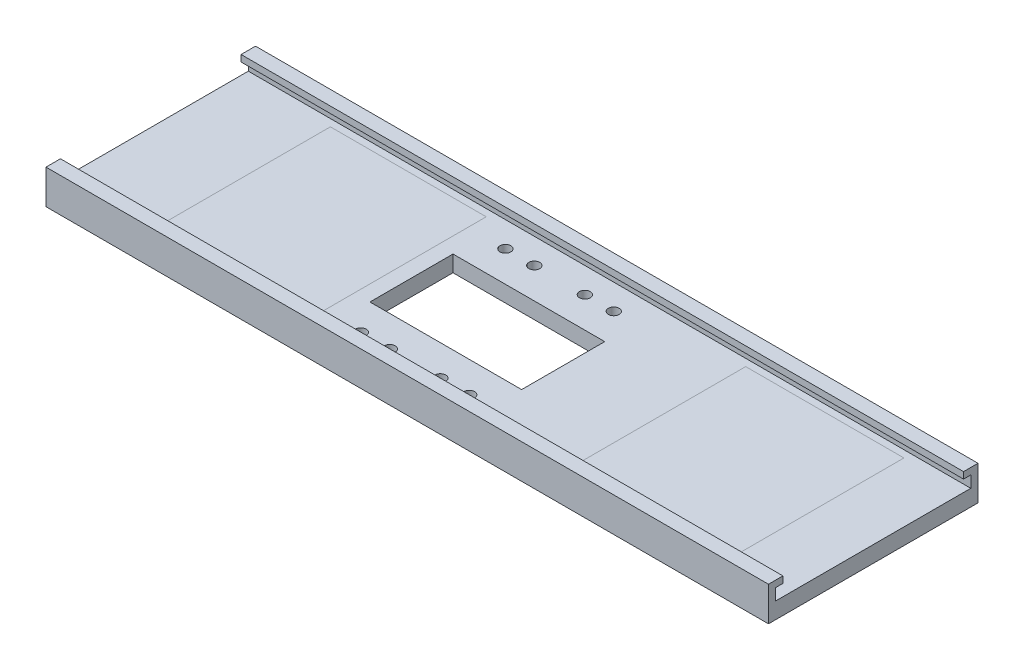
from build123d import *

# Parameters (mm, degrees)
EXTRUDE_1_DEPTH      = 180
EXTRUDE_1_DEPTH_BACK = 20
SKETCH_2_W           = 42
SKETCH_2_H           = 23
CUT_EXTRUDE_1_DEPTH  = 5.5
SKETCH_4_R           = 1.5
CUT_EXTRUDE_2_DEPTH  = 5.5
SKETCH_5_W           = 2
SKETCH_5_H           = 2.2
CUT_EXTRUDE_3_DEPTH  = 225
SKETCH_6_R           = 3
CUT_EXTRUDE_4_DEPTH  = 3.5
SKETCH_7_W           = 2
SKETCH_7_H           = 1
CUT_EXTRUDE_5_DEPTH  = 200


with BuildPart() as part:
    # 草图1 → 凸台-拉伸1 (new body, two sides)
    with BuildSketch(Plane(origin=(0, 0, 0), x_dir=(0, 0, -1), z_dir=(1, 0, 0))) as extrude_1_sk:
        Polygon((-29, 0), (29, 0), (29, 9.5), (25, 9.5), (25, 4.5), (-25, 4.5), (-25, 9.5), (-29, 9.5), align=None)
    extrude(amount=EXTRUDE_1_DEPTH)
    extrude(extrude_1_sk.sketch, amount=-EXTRUDE_1_DEPTH_BACK)

    # 草图2 → 切除-拉伸1 (cut, through all)
    with BuildSketch(Plane(origin=(0, 4.5, 0), x_dir=(1, 0, 0), z_dir=(0, 1, 0))):
        with Locations((73.17, 0)):
            Rectangle(SKETCH_2_W, SKETCH_2_H)
    extrude(amount=-CUT_EXTRUDE_1_DEPTH, mode=Mode.SUBTRACT)

    # 草图4 → 切除-拉伸2 (cut, through all)
    with BuildSketch(Plane(origin=(0, 4.5, 0), x_dir=(1, 0, 0), z_dir=(0, 1, 0))):
        with Locations((66.17, 20)):
            Circle(SKETCH_4_R)
        with Locations((80.17, 20)):
            Circle(SKETCH_4_R)
        with Locations((88.17, 20)):
            Circle(SKETCH_4_R)
        with Locations((58.17, 20)):
            Circle(SKETCH_4_R)
        with Locations((88.17, -20)):
            Circle(SKETCH_4_R)
        with Locations((80.17, -20)):
            Circle(SKETCH_4_R)
        with Locations((66.17, -20)):
            Circle(SKETCH_4_R)
        with Locations((58.17, -20)):
            Circle(SKETCH_4_R)
    extrude(amount=-CUT_EXTRUDE_2_DEPTH, mode=Mode.SUBTRACT)

    # 草图5 → 切除-拉伸3 (cut)
    with BuildSketch(Plane(origin=(180, 0, 0), x_dir=(0, 0, -1), z_dir=(1, 0, 0))):
        with Locations((-26, 6.6)):
            Rectangle(SKETCH_5_W, SKETCH_5_H)
        with Locations((26, 6.6)):
            Rectangle(SKETCH_5_W, SKETCH_5_H)
    extrude(amount=-CUT_EXTRUDE_3_DEPTH, mode=Mode.SUBTRACT)

    # 草图6 → 切除-拉伸4 (cut)
    with BuildSketch(Plane(origin=(0, 0, 0), x_dir=(-1, 0, 0), z_dir=(0, -1, 0))):
        with Locations((-97.93, 5)):
            Circle(SKETCH_6_R)
        with Locations((-48.41, 5)):
            Circle(SKETCH_6_R)
        with Locations((-48.41, -5)):
            Circle(SKETCH_6_R)
        with Locations((-97.93, -5)):
            Circle(SKETCH_6_R)
    extrude(amount=-CUT_EXTRUDE_4_DEPTH, mode=Mode.SUBTRACT)

    # 草图7 → 切除-拉伸5 (cut)
    with BuildSketch(Plane(origin=(180, 0, 0), x_dir=(0, 0, -1), z_dir=(1, 0, 0))):
        with Locations((-26, 5)):
            Rectangle(SKETCH_7_W, SKETCH_7_H)
        with Locations((26, 5)):
            Rectangle(SKETCH_7_W, SKETCH_7_H)
    extrude(amount=-CUT_EXTRUDE_5_DEPTH, mode=Mode.SUBTRACT)


solid = part.part
